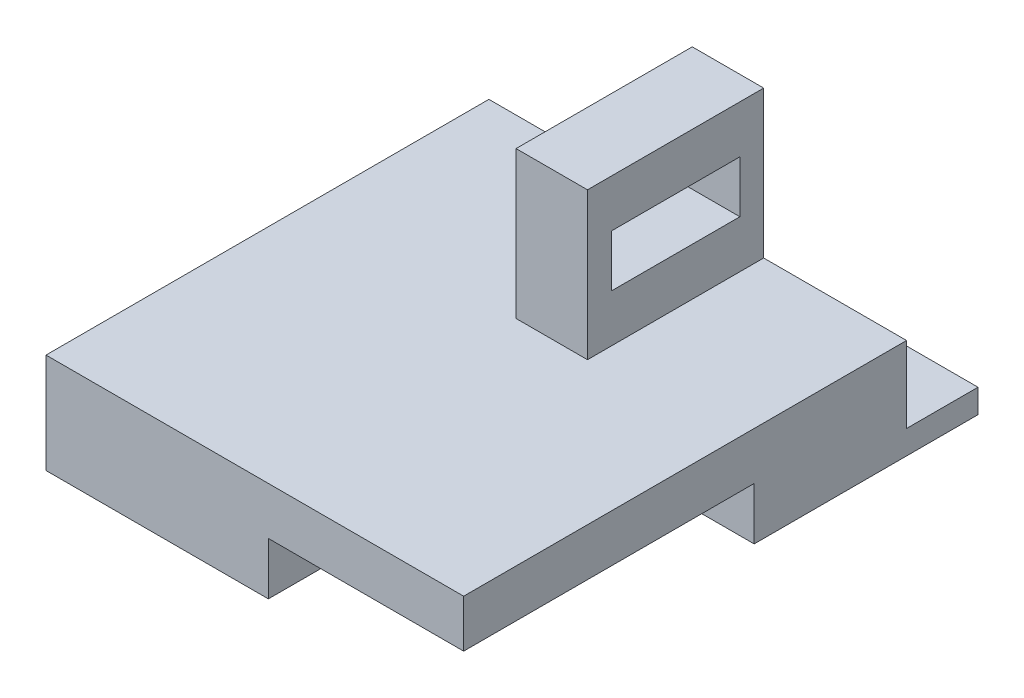
from build123d import *

# Parameters (mm, degrees)
SKETCH1_W           = 87.7
SKETCH1_H           = 108
BOSS_EXTRUDE1_DEPTH = 21
SKETCH2_W           = 41.008045073
SKETCH2_H           = 61
CUT_EXTRUDE1_DEPTH  = 11
SKETCH5_W           = 87.7
SKETCH5_H           = 15
CUT_EXTRUDE2_DEPTH  = 16
SKETCH7_W           = 15
SKETCH7_H           = 37
BOSS_EXTRUDE2_DEPTH = 30.9
SKETCH8_W           = 27
SKETCH8_H           = 10.9
CUT_EXTRUDE3_DEPTH  = 30.9


with BuildPart() as part:
    # Sketch1 → Boss-Extrude1 (new body)
    with BuildSketch(Plane(origin=(0, 0, 0), x_dir=(1, 0, 0), z_dir=(0, 1, 0))):
        with Locations((43.85, 54)):
            Rectangle(SKETCH1_W, SKETCH1_H)
    extrude(amount=BOSS_EXTRUDE1_DEPTH)

    # Sketch2 → Cut-Extrude1 (cut)
    with BuildSketch(Plane(origin=(0, 0, 0), x_dir=(-1, 0, 0), z_dir=(0, -1, 0))):
        with Locations((-67.195977464, 30.5)):
            Rectangle(SKETCH2_W, SKETCH2_H)
    extrude(amount=-CUT_EXTRUDE1_DEPTH, mode=Mode.SUBTRACT)

    # Sketch5 → Cut-Extrude2 (cut)
    with BuildSketch(Plane(origin=(0, 21, 0), x_dir=(1, 0, 0), z_dir=(0, 1, 0))):
        with Locations((43.85, 100.5)):
            Rectangle(SKETCH5_W, SKETCH5_H)
    extrude(amount=-CUT_EXTRUDE2_DEPTH, mode=Mode.SUBTRACT)

    # Sketch7 → Boss-Extrude2 (add)
    with BuildSketch(Plane(origin=(0, 21, 0), x_dir=(1, 0, 0), z_dir=(0, 1, 0))):
        with Locations((50.2, 74.5)):
            Rectangle(SKETCH7_W, SKETCH7_H)
    extrude(amount=BOSS_EXTRUDE2_DEPTH)

    # Sketch8 → Cut-Extrude3 (cut)
    with BuildSketch(Plane(origin=(57.7, 0, 0), x_dir=(0, 0, -1), z_dir=(1, 0, 0))):
        with Locations((74.5, 36.45)):
            Rectangle(SKETCH8_W, SKETCH8_H)
    extrude(amount=-CUT_EXTRUDE3_DEPTH, mode=Mode.SUBTRACT)


solid = part.part
